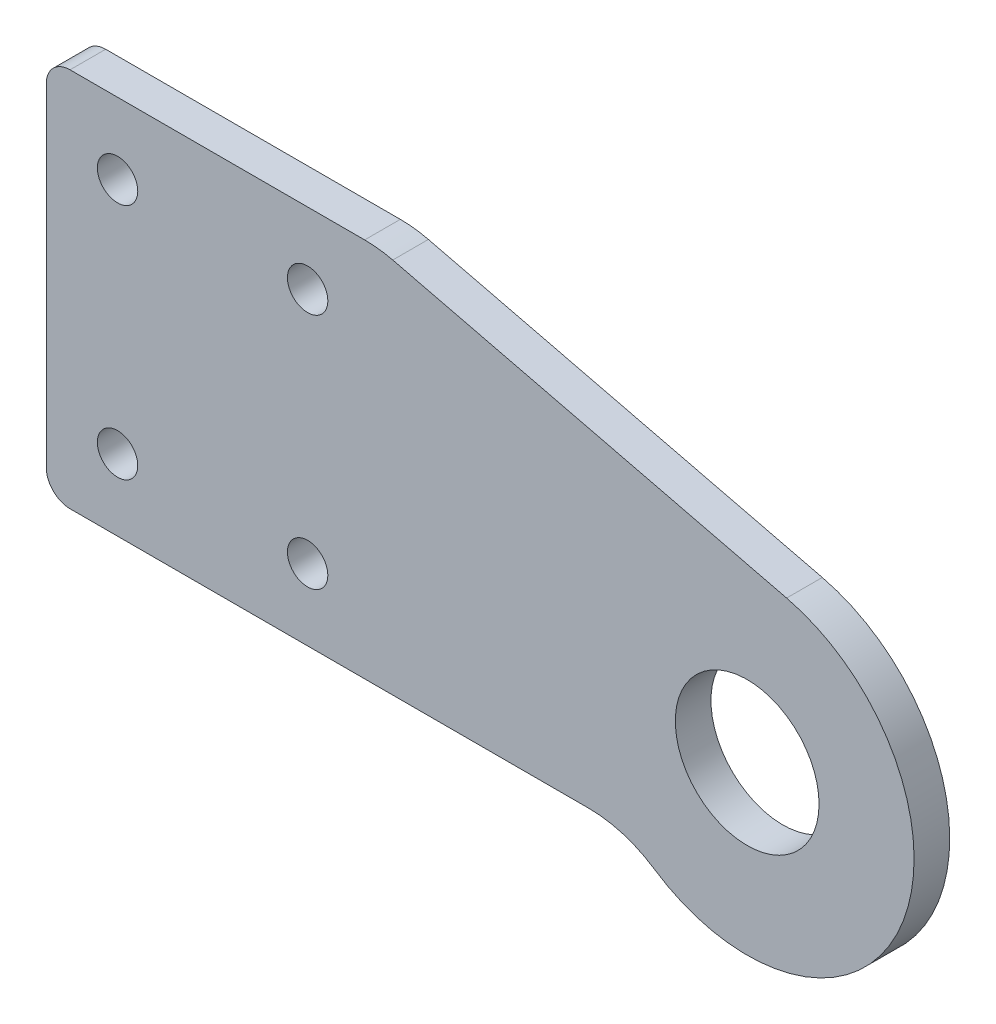
from build123d import *

# Parameters (mm, degrees)
ESQUISSE1_R        = 3.025
ESQUISSE1_R_2      = 0.85
BOSS_EXTRU_1_DEPTH = 0.75
CONG_1_R           = 5
CONG_2_R           = 1


with BuildPart() as part:
    # Esquisse1 → Boss.-Extru.1 (new body, symmetric)
    with BuildSketch(Plane.XY):
        with BuildLine():
            Line((-15.5, 11), (1.660328935, 6.825974863))
            ThreePointArc((1.660328935, 6.825974863), (6.135445446, -3.421539739), (-4.934635245, -5))
            Line((-4.934635245, -5), (-15.5, -5))
            Line((-15.5, -5), (-29.5, -5))
            Line((-29.5, -5), (-29.5, 11))
            Line((-29.5, 11), (-15.5, 11))
        make_face()
        Circle(ESQUISSE1_R, mode=Mode.SUBTRACT)
        with Locations((-26.5, 8)):
            Circle(ESQUISSE1_R_2, mode=Mode.SUBTRACT)
        with Locations((-18.5, 8)):
            Circle(ESQUISSE1_R_2, mode=Mode.SUBTRACT)
        with Locations((-18.5, -2)):
            Circle(ESQUISSE1_R_2, mode=Mode.SUBTRACT)
        with Locations((-26.5, -2)):
            Circle(ESQUISSE1_R_2, mode=Mode.SUBTRACT)
    extrude(amount=BOSS_EXTRU_1_DEPTH, both=True)

    # Congé1
    cong_1_edges = [part.edges().sort_by_distance(p)[0] for p in [
        (-15.5, 11, 0),
        (-4.934635245, -5, 0),
    ]]
    fillet(cong_1_edges, radius=CONG_1_R)

    # Congé2
    cong_2_edges = [part.edges().sort_by_distance(p)[0] for p in [
        (-29.5, 11, 0),
        (-29.5, -5, 0),
    ]]
    fillet(cong_2_edges, radius=CONG_2_R)


solid = part.part
